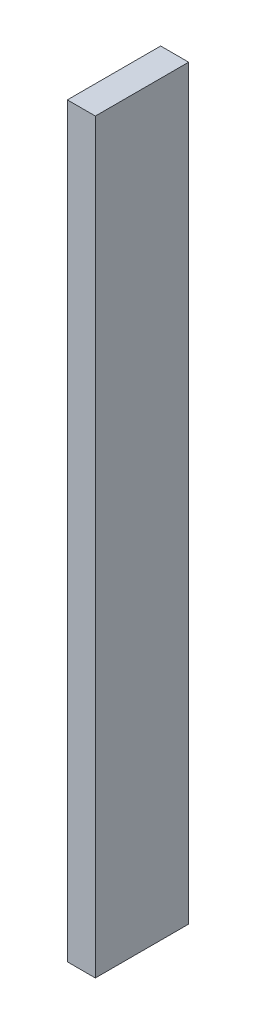
from build123d import *

# Parameters (mm, degrees)
SKETCH2_W           = 3
SKETCH2_H           = 10
BOSS_EXTRUDE1_DEPTH = 80


with BuildPart() as part:
    # Sketch2 → Boss-Extrude1 (new body)
    with BuildSketch(Plane(origin=(0, 0, 0), x_dir=(1, 0, 0), z_dir=(0, 1, 0))):
        Rectangle(SKETCH2_W, SKETCH2_H)
    extrude(amount=BOSS_EXTRUDE1_DEPTH)


solid = part.part
